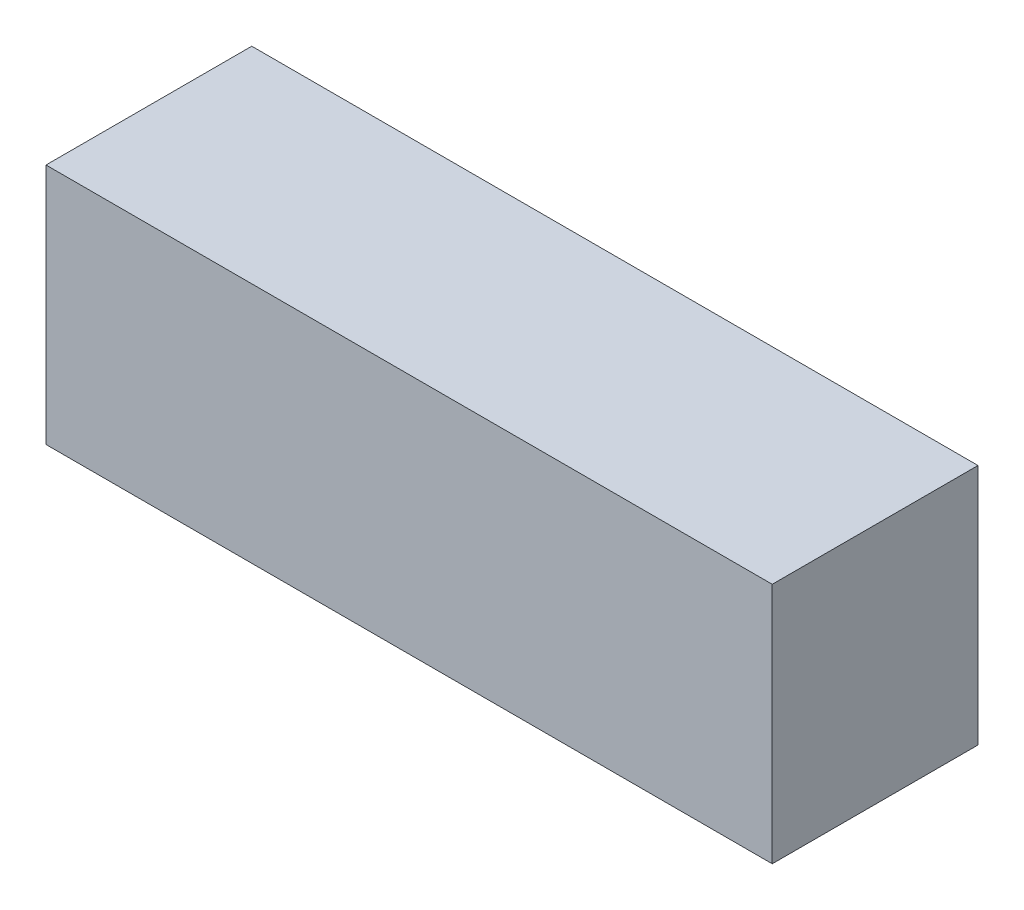
from build123d import *

# Parameters (mm, degrees)
SKETCH1_W           = 60
SKETCH1_H           = 17
BOSS_EXTRUDE1_DEPTH = 20


with BuildPart() as part:
    # Sketch1 → Boss-Extrude1 (new body)
    with BuildSketch(Plane(origin=(0, 0, 0), x_dir=(1, 0, 0), z_dir=(0, 1, 0))):
        Rectangle(SKETCH1_W, SKETCH1_H)
    extrude(amount=BOSS_EXTRUDE1_DEPTH)


solid = part.part
